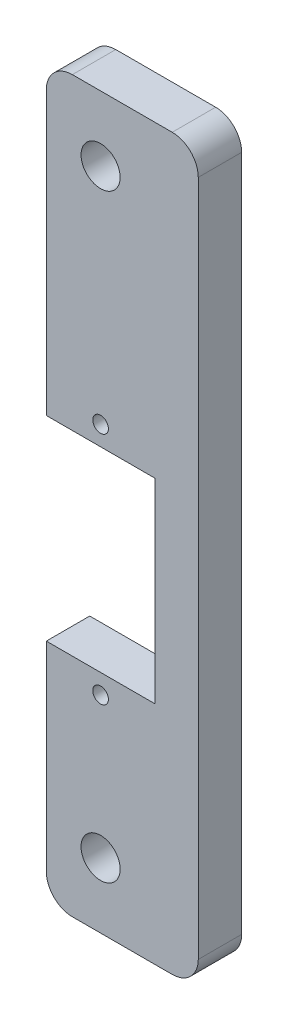
from build123d import *

# Parameters (mm, degrees)
BOSS_EXTRUDE1_DEPTH    = 5
M4_CLEARANCE_HOLE1_D   = 4.5
FILLET1_R              = 3
M1_6_CLEARANCE_HOLE1_D = 1.8


with BuildPart() as part:
    # Sketch2 → Boss-Extrude1 (new body)
    with BuildSketch(Plane.XY):
        Polygon((11.25, 46.75), (-6.25, 46.75), (-6.25, 11.25), (6.25, 11.25), (6.25, -11.25), (-6.25, -11.25), (-6.25, -37.25), (11.25, -37.25), align=None)
    extrude(amount=BOSS_EXTRUDE1_DEPTH)

    # M4 Clearance Hole1 (through all)
    with Locations(Plane(origin=(0, 0, 0), x_dir=(1, 0, 0), z_dir=(0, 0, -1))):
        with Locations((0, -39.25), (0, 29.75)):
            Hole(M4_CLEARANCE_HOLE1_D / 2)

    # Fillet1
    fillet1_edges = [part.edges().sort_by_distance(p)[0] for p in [
        (-6.25, 46.75, 2.5),
        (11.25, 46.75, 2.5),
        (11.25, -37.25, 2.5),
        (-6.25, -37.25, 2.5),
    ]]
    fillet(fillet1_edges, radius=FILLET1_R)

    # M1.6 Clearance Hole1 (through all)
    with Locations(Plane(origin=(0, 0, 0), x_dir=(1, 0, 0), z_dir=(0, 0, -1))):
        with Locations((0, -13.5), (0, 13.5)):
            Hole(M1_6_CLEARANCE_HOLE1_D / 2)


solid = part.part
